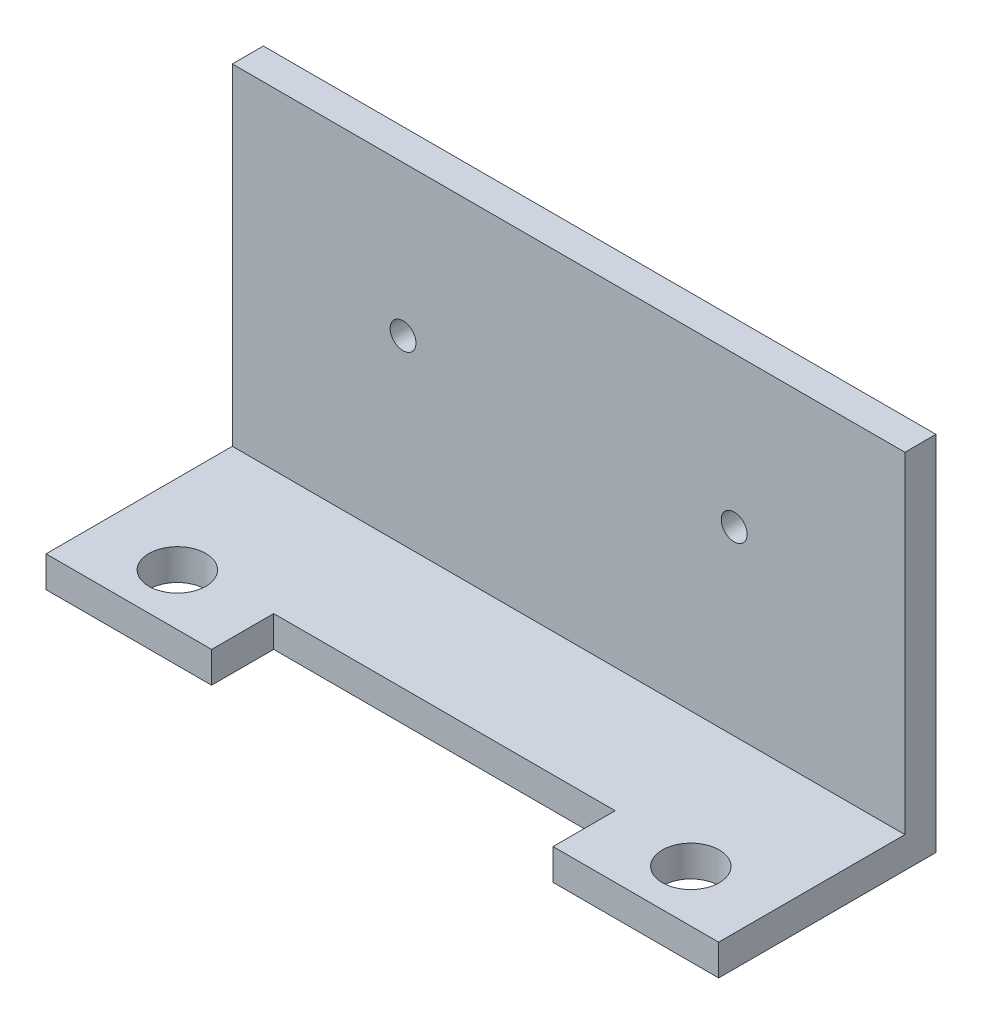
from build123d import *

# Parameters (mm, degrees)
SKETCH1_R           = 2.75
BOSS_EXTRUDE1_DEPTH = 3
SKETCH2_W           = 65
SKETCH2_H           = 3
BOSS_EXTRUDE2_DEPTH = 35
SKETCH3_R           = 1.25
CUT_EXTRUDE1_DEPTH  = 4


with BuildPart() as part:
    # Sketch1 → Boss-Extrude1 (new body)
    with BuildSketch(Plane(origin=(0, 0, 0), x_dir=(1, 0, 0), z_dir=(0, 1, 0))):
        Polygon((0, 0), (16, 0), (16, 6), (49, 6), (49, 0), (65, 0), (65, 18), (0, 18), align=None)
        with Locations((7.69, 5)):
            Circle(SKETCH1_R, mode=Mode.SUBTRACT)
        with Locations((57.31, 5)):
            Circle(SKETCH1_R, mode=Mode.SUBTRACT)
    extrude(amount=BOSS_EXTRUDE1_DEPTH)

    # Sketch2 → Boss-Extrude2 (add)
    with BuildSketch(Plane(origin=(0, 0, 0), x_dir=(1, 0, 0), z_dir=(0, 1, 0))):
        with Locations((32.5, 19.5)):
            Rectangle(SKETCH2_W, SKETCH2_H)
    extrude(amount=BOSS_EXTRUDE2_DEPTH)

    # Sketch3 → Cut-Extrude1 (cut, through all)
    with BuildSketch(Plane.XY.offset(-18)):
        with Locations((16.5, 20.5)):
            Circle(SKETCH3_R)
        with Locations((48.5, 20.5)):
            Circle(SKETCH3_R)
    extrude(amount=-CUT_EXTRUDE1_DEPTH, mode=Mode.SUBTRACT)


solid = part.part
